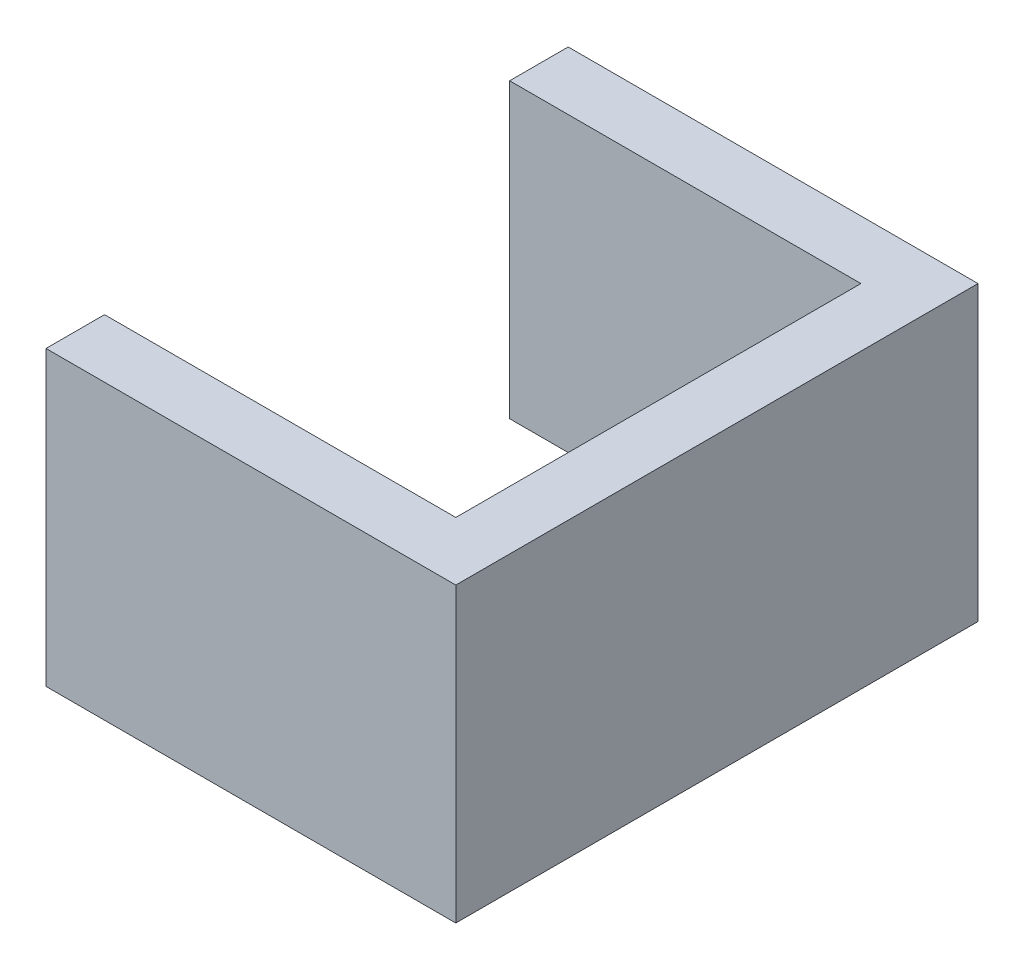
from build123d import *

# Parameters (mm, degrees)
BOSS_EXTRUDE1_DEPTH = 50


with BuildPart() as part:
    # Sketch1 → Boss-Extrude1 (new body)
    with BuildSketch(Plane(origin=(0, 0, 0), x_dir=(1, 0, 0), z_dir=(0, 1, 0))):
        Polygon((-70.765034965, 34.8), (-10.765034965, 34.8), (-10.765034965, -34.4), (-70.765034965, -34.4), (-70.765034965, -44.4), (-0.765034965, -44.4), (-0.765034965, 44.8), (-70.765034965, 44.8), align=None)
    extrude(amount=BOSS_EXTRUDE1_DEPTH)


solid = part.part
